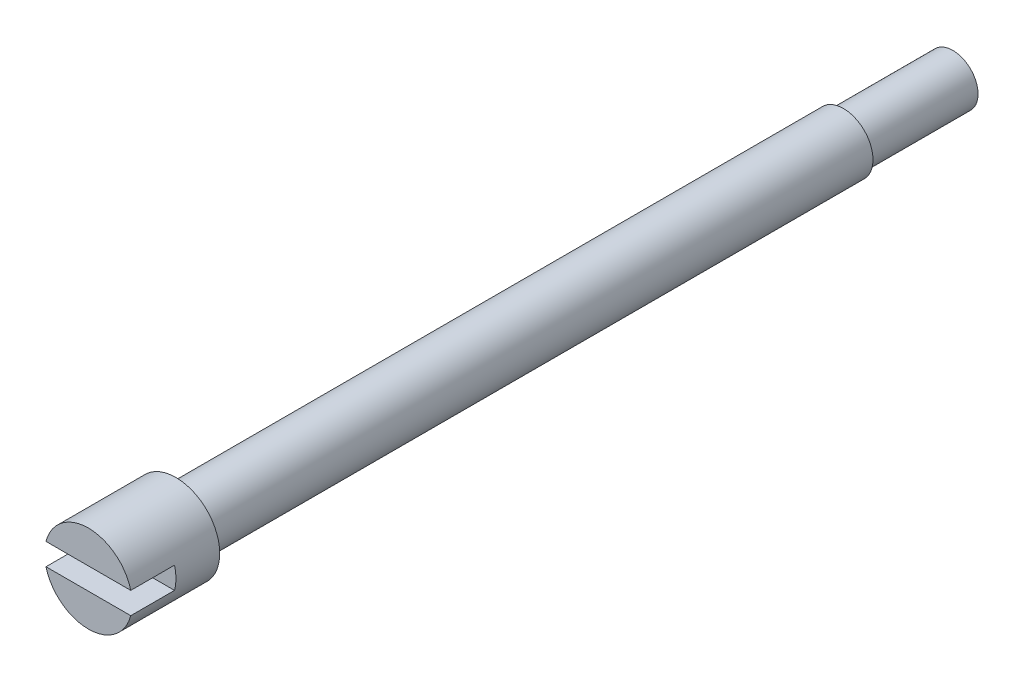
from build123d import *

# Parameters (mm, degrees)
SKETCH1_R           = 1.35
BOSS_EXTRUDE1_DEPTH = 35.5
SKETCH2_R           = 2
BOSS_EXTRUDE2_DEPTH = 4
SKETCH3_W           = 4
SKETCH3_H           = 1
CUT_EXTRUDE1_DEPTH  = 2
SKETCH4_OUTSIDE_W   = 13.98
SKETCH4_OUTSIDE_H   = 13.98
SKETCH4_OUTSIDE_R   = 1.15
CUT_EXTRUDE2_DEPTH  = 5


with BuildPart() as part:
    # Sketch1 → Boss-Extrude1 (new body)
    with BuildSketch(Plane.XY):
        Circle(SKETCH1_R)
    extrude(amount=BOSS_EXTRUDE1_DEPTH)

    # Sketch2 → Boss-Extrude2 (add)
    with BuildSketch(Plane.XY.offset(35.5)):
        Circle(SKETCH2_R)
    extrude(amount=BOSS_EXTRUDE2_DEPTH)

    # Sketch3 → Cut-Extrude1 (cut)
    with BuildSketch(Plane.XY.offset(39.5)):
        Rectangle(SKETCH3_W, SKETCH3_H)
    extrude(amount=-CUT_EXTRUDE1_DEPTH, mode=Mode.SUBTRACT)

    # Sketch4 outside → Cut-Extrude2 (cut)
    with BuildSketch(Plane(origin=(0, 0, 0), x_dir=(-1, 0, 0), z_dir=(0, 0, -1))):
        Rectangle(SKETCH4_OUTSIDE_W, SKETCH4_OUTSIDE_H)
        Circle(SKETCH4_OUTSIDE_R, mode=Mode.SUBTRACT)
    extrude(amount=-CUT_EXTRUDE2_DEPTH, mode=Mode.SUBTRACT)


solid = part.part
